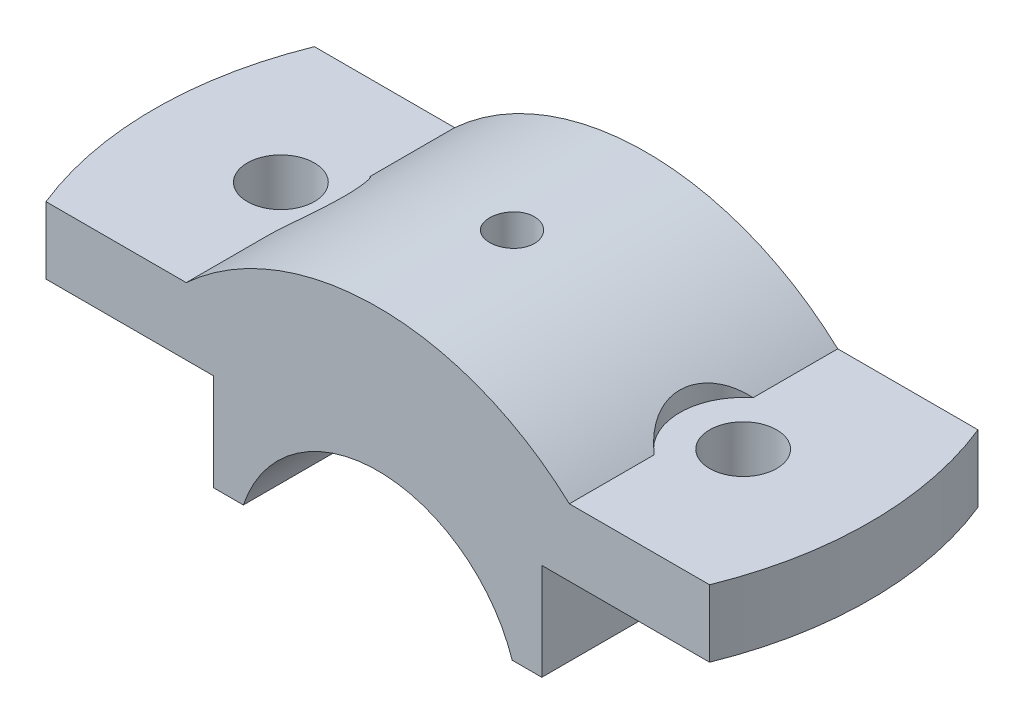
from build123d import *

# Parameters (mm, degrees)
BOSS_EXTRUDE1_DEPTH = 18
CUT_EXTRUDE1_DEPTH  = 39
SKETCH3_R           = 4.5
CUT_EXTRUDE2_DEPTH  = 58
CUT_EXTRUDE3_DEPTH  = 64


with BuildPart() as part:
    # Sketch1 → Boss-Extrude1 (new body, symmetric)
    with BuildSketch(Plane.XY):
        with BuildLine():
            Line((18.027756377, 6), (22, 6))
            Line((22, 6), (22, 19))
            Line((22, 19), (50, 19))
            Line((50, 19), (50, 28))
            Line((50, 28), (25.690465157, 28))
            ThreePointArc((25.690465157, 28), (0, 38), (-25.690465157, 28))
            Line((-25.690465157, 28), (-50, 28))
            Line((-50, 28), (-50, 19))
            Line((-50, 19), (-22, 19))
            Line((-22, 19), (-22, 6))
            Line((-22, 6), (-18.027756377, 6))
            ThreePointArc((-18.027756377, 6), (0, 19), (18.027756377, 6))
        make_face()
    extrude(amount=BOSS_EXTRUDE1_DEPTH, both=True)

    # Sketch2 → Cut-Extrude1 (cut, through all)
    with BuildSketch(Plane(origin=(0, 0, 0), x_dir=(1, 0, 0), z_dir=(0, 1, 0))):
        with BuildLine():
            Line((-44.497190923, 18), (-50, 18))
            Line((-50, 18), (-50, -18))
            Line((-50, -18), (-44.497190923, -18))
            ThreePointArc((-44.497190923, -18), (-48, 0), (-44.497190923, 18))
        make_face()
    cut_extrude1 = extrude(amount=CUT_EXTRUDE1_DEPTH, mode=Mode.SUBTRACT)

    # Sketch3 → Cut-Extrude2 (cut)
    with BuildSketch(Plane(origin=(0, 28, 0), x_dir=(1, 0, 0), z_dir=(0, 1, 0))):
        with Locations(Location((-31, 0, 0), (0, 0, 180))):  # turned: the seam where the file's is
            Circle(SKETCH3_R)
    cut_extrude2 = extrude(amount=-CUT_EXTRUDE2_DEPTH, mode=Mode.SUBTRACT)

    # Sketch4 → Cut-Extrude3 (cut)
    with BuildSketch(Plane(origin=(0, 28, 0), x_dir=(1, 0, 0), z_dir=(0, 1, 0))):
        with BuildLine():
            Line((-25.690465157, -6.637683312), (-25.690465157, 6.637683312))
            ThreePointArc((-25.690465157, 6.637683312), (-22.5, 0), (-25.690465157, -6.637683312))
        make_face()
    cut_extrude3 = extrude(amount=CUT_EXTRUDE3_DEPTH, mode=Mode.SUBTRACT)

    # Mirror5: Cut-Extrude1, Cut-Extrude2, Cut-Extrude3 across plane
    add(cut_extrude1.mirror(Plane(origin=(0, 0, 0), x_dir=(0, 0, 1), z_dir=(1, 0, 0))), mode=Mode.SUBTRACT)
    add(cut_extrude2.mirror(Plane(origin=(0, 0, 0), x_dir=(0, 0, 1), z_dir=(1, 0, 0))), mode=Mode.SUBTRACT)
    add(cut_extrude3.mirror(Plane(origin=(0, 0, 0), x_dir=(0, 0, 1), z_dir=(1, 0, 0))), mode=Mode.SUBTRACT)

    # Sketch7 → CBORE for M5 Hex Head Bolt1 (revolve, cut)
    with BuildSketch(Plane(origin=(0, 38, 0), x_dir=(0, 0, 1), z_dir=(1, 0, 0))):
        Polygon((0, 0), (0, 32), (2.5, 32), (2.5, 13.495), (2.995, 13), (3, 13), (3, 0), align=None)
    revolve(axis=Axis((0, 44.35, 0), (0, -1, 0)), mode=Mode.SUBTRACT)


solid = part.part
